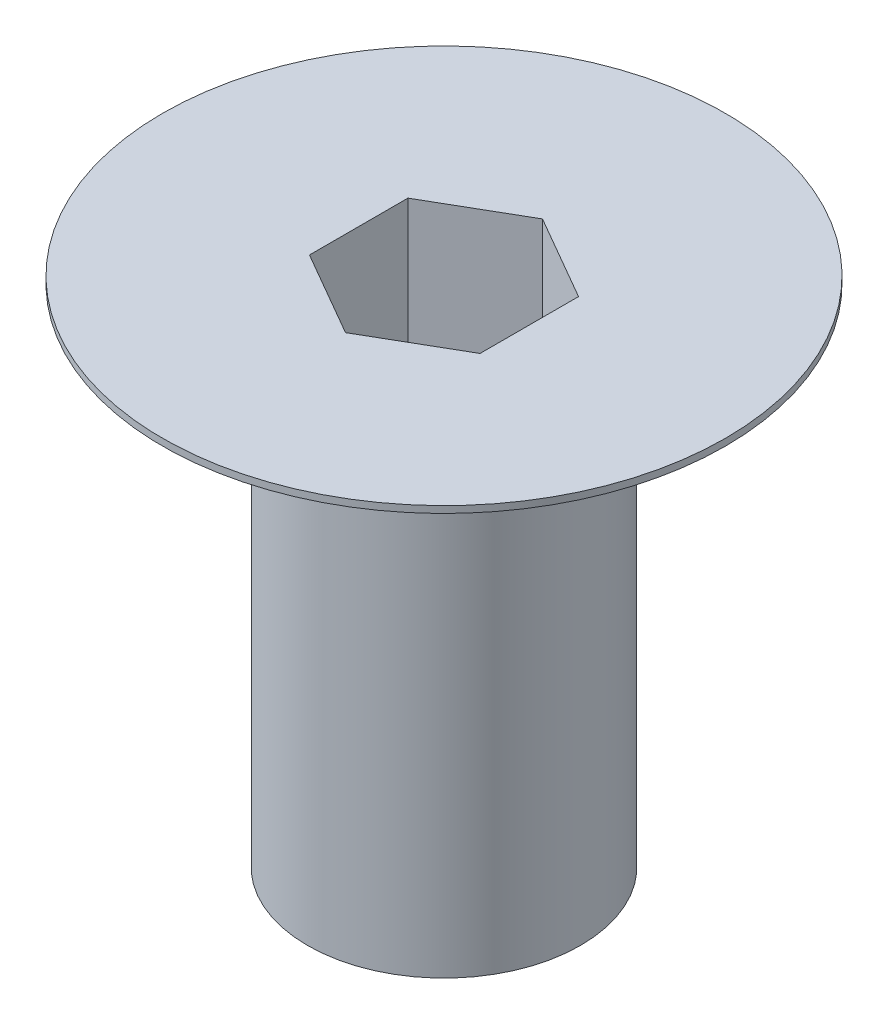
from build123d import *

# Parameters (mm, degrees)
CORTE_EXTRUS_O1_DEPTH = 4


with BuildPart() as part:
    # Esboço1 → Revolução1 (revolve)
    with BuildSketch(Plane.XY):
        Polygon((0, 0), (4, 0), (4, 12.346261356), (8.25, 14.8), (8.25, 15), (0, 15), align=None)
    revolve(axis=Axis((0, 15, 0), (0, -1, 0)))

    # Esboço2 → Corte-extrusão1 (cut)
    with BuildSketch(Plane(origin=(0, 15, 0), x_dir=(1, 0, 0), z_dir=(0, 1, 0))):
        Polygon((0, 2.886751346), (-2.5, 1.443375673), (-2.5, -1.443375673), (0, -2.886751346), (2.5, -1.443375673), (2.5, 1.443375673), align=None)
    extrude(amount=-CORTE_EXTRUS_O1_DEPTH, mode=Mode.SUBTRACT)


solid = part.part
